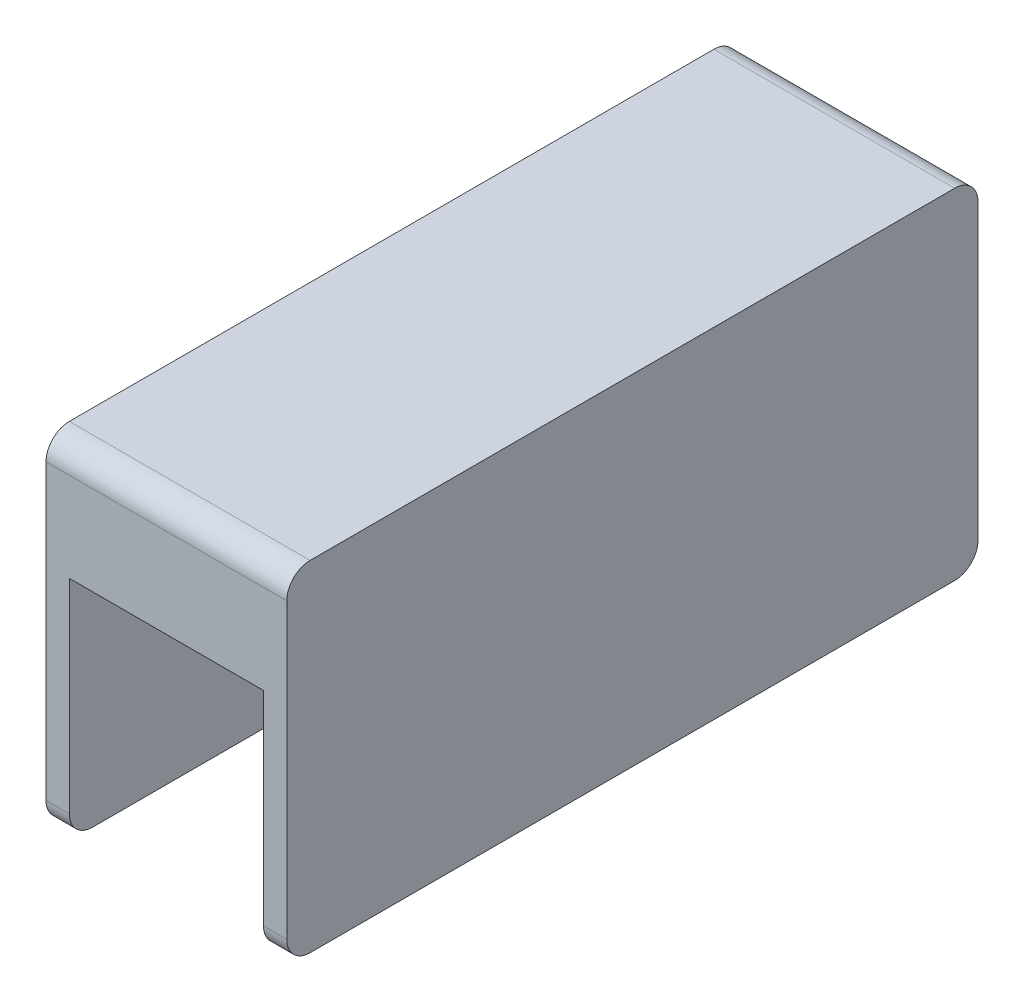
from build123d import *

# Parameters (mm, degrees)
RESSALTO_EXTRUS_O2_DEPTH = 25
RESSALTO_EXTRUS_O3_DEPTH = 3
RESSALTO_EXTRUS_O4_DEPTH = 3


with BuildPart() as part:
    # Esboço2 → Ressalto-extrusão2 (new body)
    with BuildSketch(Plane(origin=(0, 0, 0), x_dir=(0, 0, -1), z_dir=(1, 0, 0))):
        with BuildLine():
            Line((2.90159992, -0.062465938), (-35.09840008, -0.062465938))
            Line((-35.09840008, -0.062465938), (-39.886084903, -0.062465938))
            ThreePointArc((-39.886084903, -0.062465938), (-45.202180234, 1.467638524), (-48.891439328, 5.589707975))
            ThreePointArc((-48.891439328, 5.589707975), (-52.096536948, 9.772081499), (-56.69840008, 12.338743681))
            ThreePointArc((-56.69840008, 12.338743681), (-59.373224015, 11.895603401), (-60.59840008, 9.476926077))
            Line((-60.59840008, 9.476926077), (-60.59840008, 20.976926077))
            ThreePointArc((-60.59840008, 20.976926077), (-59.719720424, 23.09824642), (-57.59840008, 23.976926077))
            Line((-57.59840008, 23.976926077), (25.40159992, 23.976926077))
            ThreePointArc((25.40159992, 23.976926077), (27.522920263, 23.09824642), (28.40159992, 20.976926077))
            Line((28.40159992, 20.976926077), (28.40159992, 9.476926077))
            ThreePointArc((28.40159992, 9.476926077), (27.176423855, 11.895603401), (24.50159992, 12.338743681))
            ThreePointArc((24.50159992, 12.338743681), (19.899736788, 9.772081499), (16.694639168, 5.589707975))
            ThreePointArc((16.694639168, 5.589707975), (13.005380073, 1.467638524), (7.689284743, -0.062465938))
            Line((7.689284743, -0.062465938), (2.90159992, -0.062465938))
        make_face()
    extrude(amount=RESSALTO_EXTRUS_O2_DEPTH)

    # Esboço3 → Ressalto-extrusão3 (add)
    with BuildSketch(Plane.ZY):
        with BuildLine():
            Line((60.59840008, 15.226926077), (60.59840008, 20.976926077))
            ThreePointArc((60.59840008, 20.976926077), (59.719720424, 23.09824642), (57.59840008, 23.976926077))
            Line((57.59840008, 23.976926077), (16.09840008, 23.976926077))
            Line((16.09840008, 23.976926077), (-25.40159992, 23.976926077))
            ThreePointArc((-25.40159992, 23.976926077), (-27.522920263, 23.09824642), (-28.40159992, 20.976926077))
            Line((-28.40159992, 20.976926077), (-28.40159992, 15.226926077))
            Line((-28.40159992, 15.226926077), (-28.40159992, -16.773073923))
            ThreePointArc((-28.40159992, -16.773073923), (-27.522920263, -18.894394267), (-25.40159992, -19.773073923))
            Line((-25.40159992, -19.773073923), (57.59840008, -19.773073923))
            ThreePointArc((57.59840008, -19.773073923), (59.719720424, -18.894394267), (60.59840008, -16.773073923))
            Line((60.59840008, -16.773073923), (60.59840008, 15.226926077))
        make_face()
    extrude(amount=RESSALTO_EXTRUS_O3_DEPTH)

    # Esboço4 → Ressalto-extrusão4 (add)
    with BuildSketch(Plane(origin=(25, 0, 0), x_dir=(0, 0, -1), z_dir=(1, 0, 0))):
        with BuildLine():
            Line((-16.09840008, 23.976926077), (25.40159992, 23.976926077))
            ThreePointArc((25.40159992, 23.976926077), (27.522920263, 23.09824642), (28.40159992, 20.976926077))
            Line((28.40159992, 20.976926077), (28.40159992, 15.226926077))
            Line((28.40159992, 15.226926077), (28.40159992, -16.773073923))
            ThreePointArc((28.40159992, -16.773073923), (27.522920263, -18.894394267), (25.40159992, -19.773073923))
            Line((25.40159992, -19.773073923), (-57.59840008, -19.773073923))
            ThreePointArc((-57.59840008, -19.773073923), (-59.719720424, -18.894394267), (-60.59840008, -16.773073923))
            Line((-60.59840008, -16.773073923), (-60.59840008, 15.226926077))
            Line((-60.59840008, 15.226926077), (-60.59840008, 20.976926077))
            ThreePointArc((-60.59840008, 20.976926077), (-59.719720424, 23.09824642), (-57.59840008, 23.976926077))
            Line((-57.59840008, 23.976926077), (-16.09840008, 23.976926077))
        make_face()
    extrude(amount=RESSALTO_EXTRUS_O4_DEPTH)


solid = part.part
